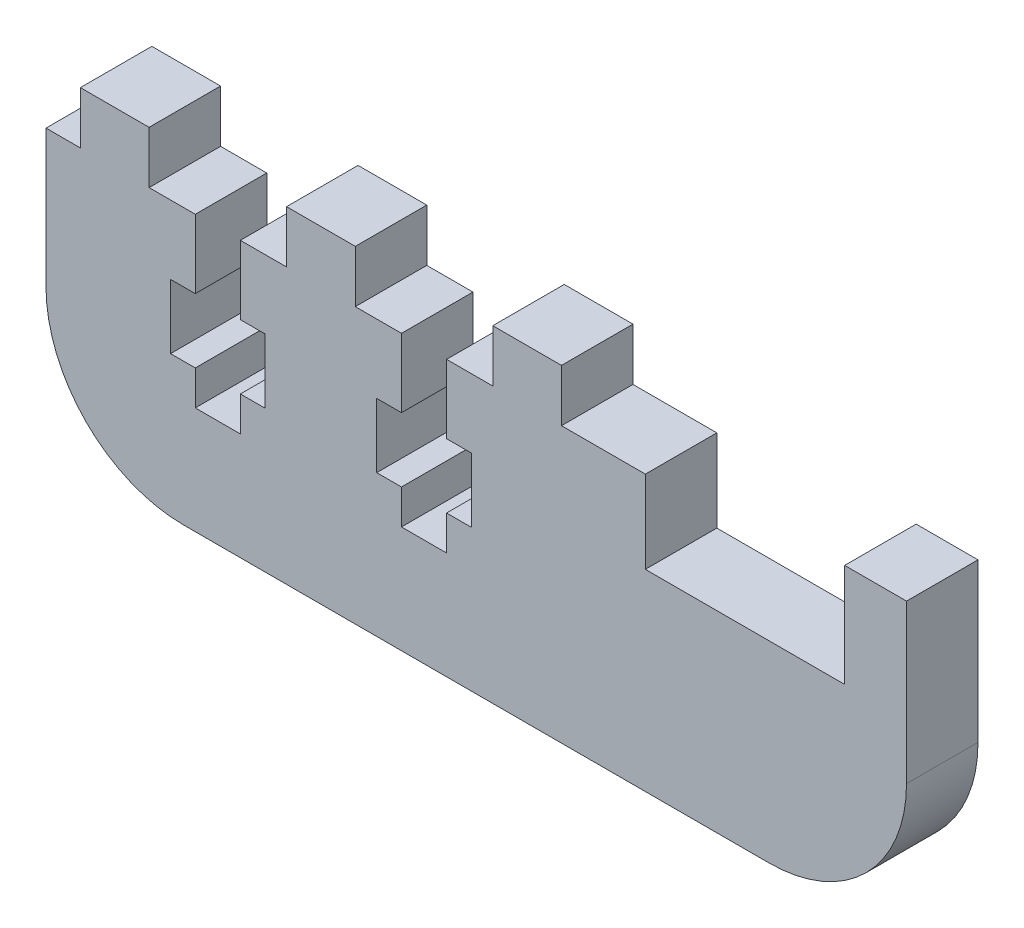
from build123d import *

# Parameters (mm, degrees)
BOSS_EXTRUDE1_DEPTH = 6.604
FILLET1_R           = 12.7
CUT_EXTRUDE1_DEPTH  = 7.604
SKETCH3_W           = 6.35
SKETCH3_H           = 4.826
BOSS_EXTRUDE2_DEPTH = 6.604


with BuildPart() as part:
    # Sketch1 → Boss-Extrude1 (new body)
    with BuildSketch(Plane.XY):
        Polygon((-11.43, -1.905), (-11.43, -9.525), (6.985, -9.525), (6.985, 0), (12.7, 0), (12.7, -27.305), (-66.802, -27.305), (-66.802, -1.905), (-12.827, -1.905), align=None)
    extrude(amount=BOSS_EXTRUDE1_DEPTH)

    # Fillet1
    fillet1_edges = [part.edges().sort_by_distance(p)[0] for p in [
        (12.7, -27.305, 3.302),
        (-66.802, -27.305, 3.302),
    ]]
    fillet(fillet1_edges, radius=FILLET1_R)

    # Sketch2 → Cut-Extrude1 (cut, through all)
    with BuildSketch(Plane.XY.offset(6.604)):
        Polygon((-53.0098, -1.905), (-53.0098, -8.255), (-55.2958, -8.255), (-55.2958, -14.1986), (-53.0098, -14.1986), (-53.0098, -17.399), (-48.8442, -17.399), (-48.8442, -14.1986), (-46.5582, -14.1986), (-46.5582, -8.255), (-48.8442, -8.255), (-48.8442, -1.905), align=None)
        Polygon((-33.9598, -1.905), (-33.9598, -8.255), (-36.2458, -8.255), (-36.2458, -14.1986), (-33.9598, -14.1986), (-33.9598, -17.399), (-29.7942, -17.399), (-29.7942, -14.1986), (-27.5082, -14.1986), (-27.5082, -8.255), (-29.7942, -8.255), (-29.7942, -1.905), align=None)
    extrude(amount=-CUT_EXTRUDE1_DEPTH, mode=Mode.SUBTRACT)

    # Sketch3 → Boss-Extrude2 (add)
    with BuildSketch(Plane.XY.offset(6.604)):
        with Locations((-60.452, 0.508)):
            Rectangle(SKETCH3_W, SKETCH3_H)
        with Locations((-41.402, 0.508)):
            Rectangle(SKETCH3_W, SKETCH3_H)
        with Locations((-22.352, 0.508)):
            Rectangle(SKETCH3_W, SKETCH3_H)
    extrude(amount=-BOSS_EXTRUDE2_DEPTH)


solid = part.part
